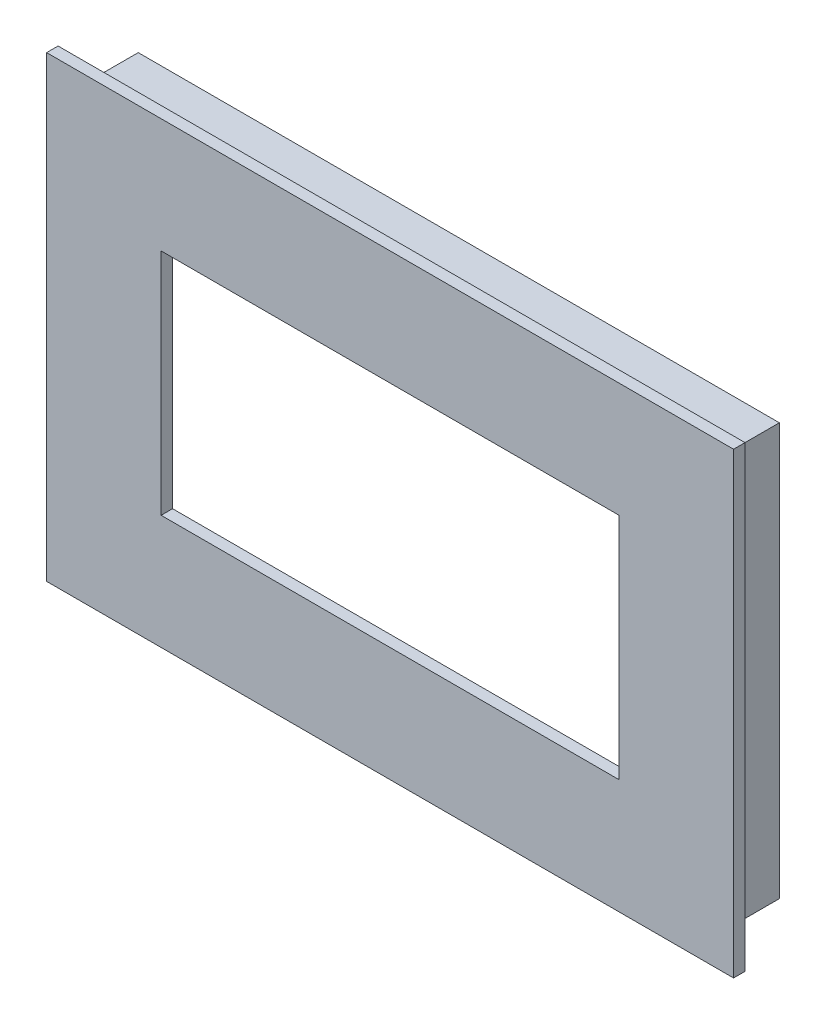
from build123d import *

# Parameters (mm, degrees)
SKETCH1_W           = 56
SKETCH1_H           = 36
SKETCH1_W_2         = 54
SKETCH1_H_2         = 34
BOSS_EXTRUDE1_DEPTH = 5
SKETCH3_W           = 60
SKETCH3_H           = 40
BOSS_EXTRUDE3_DEPTH = 1
SKETCH4_W           = 40
SKETCH4_H           = 20
CUT_EXTRUDE2_DEPTH  = 7


with BuildPart() as part:
    # Sketch1 → Boss-Extrude1 (new body)
    with BuildSketch(Plane.XY):
        Rectangle(SKETCH1_W, SKETCH1_H)
        Rectangle(SKETCH1_W_2, SKETCH1_H_2, mode=Mode.SUBTRACT)
    extrude(amount=BOSS_EXTRUDE1_DEPTH)

    # Sketch3 → Boss-Extrude3 (add)
    with BuildSketch(Plane.XY.offset(5)):
        Rectangle(SKETCH3_W, SKETCH3_H)
    extrude(amount=BOSS_EXTRUDE3_DEPTH)

    # Sketch4 → Cut-Extrude2 (cut, through all)
    with BuildSketch(Plane.XY.offset(6)):
        Rectangle(SKETCH4_W, SKETCH4_H)
    extrude(amount=-CUT_EXTRUDE2_DEPTH, mode=Mode.SUBTRACT)


solid = part.part
